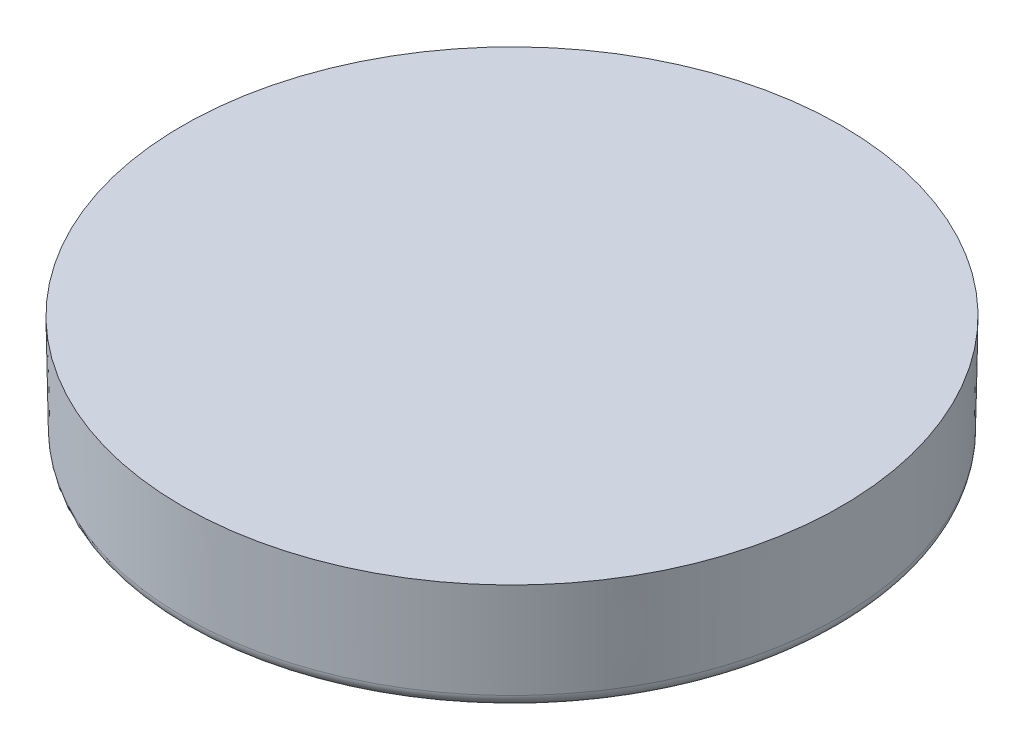
from build123d import *

# Parameters (mm, degrees)
SKETCH1_R           = 19.05
BOSS_EXTRUDE1_DEPTH = 6.35
BOSS_EXTRUDE1_DRAFT = -1
CUT_EXTRUDE3_DEPTH  = 20.05
CIRPATTERN3_COUNT   = 24
SKETCH7_R           = 19.05
SKETCH7_R_2         = 16.637
BOSS_EXTRUDE3_DEPTH = 6.35
BOSS_EXTRUDE3_DRAFT = -1
FILLET2_R           = 0.762


with BuildPart() as part:
    # Sketch1 → Boss-Extrude1 (with draft: the straight prism first)
    with BuildSketch(Plane(origin=(0, 0, 0), x_dir=(1, 0, 0), z_dir=(0, 1, 0))):
        Circle(SKETCH1_R)
    extrude(amount=-BOSS_EXTRUDE1_DEPTH)
    # Boss-Extrude1: the draft: its side faces are tilted about the plane it starts from
    boss_extrude1_sides = [part.faces().sort_by_distance(p)[0] for p in [
        (-19.05, -3.175, 0),
    ]]
    draft(boss_extrude1_sides, Plane(origin=(0, 0, 0), x_dir=(1, 0, 0), z_dir=(0, 1, 0)), BOSS_EXTRUDE1_DRAFT)

    # Sketch6 → Cut-Extrude3 (cut, through all)
    with BuildSketch(Plane.XY):
        Polygon((0, -2.54), (-6.985, -9.525), (6.985, -9.525), align=None)
    cut_extrude3 = extrude(amount=-CUT_EXTRUDE3_DEPTH, mode=Mode.SUBTRACT)

    # CirPattern3: Cut-Extrude3 ×24 about axis
    cirpattern3_axis = Axis((0, 0, 0), (0, 1, 0))
    for i in range(1, CIRPATTERN3_COUNT):
        add(cut_extrude3.rotate(cirpattern3_axis, i * 360 / CIRPATTERN3_COUNT), mode=Mode.SUBTRACT)


with BuildPart() as boss_extrude3_tool:
    # Sketch7 → Boss-Extrude3 (with draft: the straight prism first)
    with BuildSketch(Plane(origin=(0, 0, 0), x_dir=(1, 0, 0), z_dir=(0, 1, 0))):
        Circle(SKETCH7_R)
        Circle(SKETCH7_R_2, mode=Mode.SUBTRACT)
    extrude(amount=-BOSS_EXTRUDE3_DEPTH)
    # Boss-Extrude3: the draft: its side faces are tilted about the plane it starts from
    boss_extrude3_sides = [boss_extrude3_tool.faces().sort_by_distance(p)[0] for p in [
        (-19.05, -3.175, 0),
        (-16.637, -3.175, 0),
    ]]
    draft(boss_extrude3_sides, Plane(origin=(0, 0, 0), x_dir=(1, 0, 0), z_dir=(0, 1, 0)), BOSS_EXTRUDE3_DRAFT)


with BuildPart() as part_1:
    add(part.part)

    # Boss-Extrude3: add boss_extrude3_tool
    add(boss_extrude3_tool.part)

    # Fillet2
    fillet2_edges = [part_1.edges().sort_by_distance(p)[0] for p in [
        (-18.939160338, -6.35, 0),
        (-16.747839662, -6.35, 0),
    ]]
    fillet(fillet2_edges, radius=FILLET2_R)


solid = part_1.part
